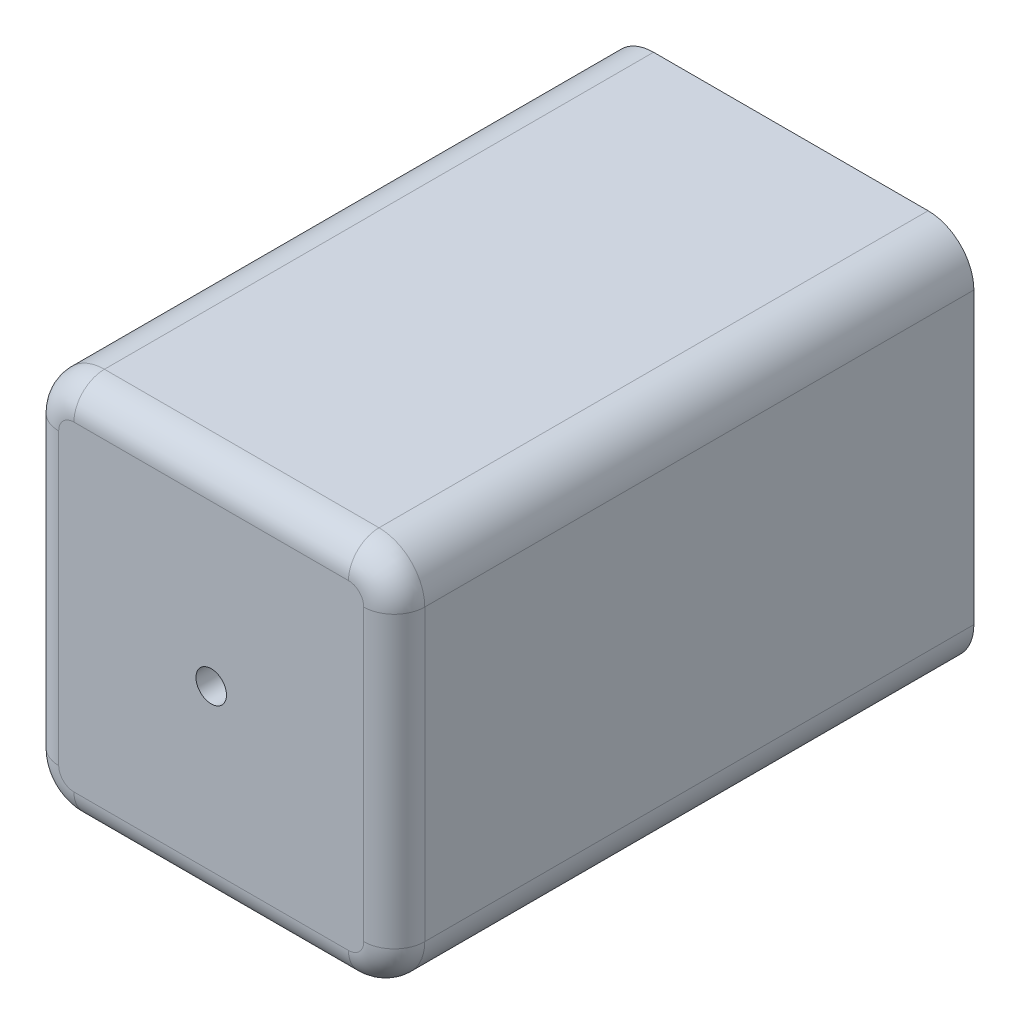
from build123d import *

# Parameters (mm, degrees)
SCHIZZO2_W                   = 190
SCHIZZO2_H                   = 125
ESTRUSIONE_ESTRUSIONE1_DEPTH = 120
RACCORDO1_R                  = 15
RACCORDO2_R                  = 10
SCHIZZO3_R                   = 5
TAGLIO_ESTRUSIONE1_DEPTH     = 191


with BuildPart() as part:
    # Schizzo2 → Estrusione-Estrusione1 (new body)
    with BuildSketch(Plane(origin=(0, 0, 0), x_dir=(0, 0, -1), z_dir=(1, 0, 0))):
        Rectangle(SCHIZZO2_W, SCHIZZO2_H)
    extrude(amount=ESTRUSIONE_ESTRUSIONE1_DEPTH)

    # Raccordo1
    raccordo1_edges = [part.edges().sort_by_distance(p)[0] for p in [
        (120, -62.5, 0),
        (0, -62.5, 0),
        (0, 62.5, 0),
        (120, 62.5, 0),
    ]]
    fillet(raccordo1_edges, radius=RACCORDO1_R)

    # Raccordo2
    raccordo2_edges = [part.edges().sort_by_distance(p)[0] for p in [
        (120, 0, 95),
        (0, 0, 95),
        (60, -62.5, 95),
        (60, 62.5, 95),
        (4.393398282, -58.106601718, 95),
        (4.393398282, 58.106601718, 95),
        (115.606601718, -58.106601718, 95),
        (115.606601718, 58.106601718, 95),
    ]]
    fillet(raccordo2_edges, radius=RACCORDO2_R)

    # Schizzo3 → Taglio-Estrusione1 (cut, through all)
    with BuildSketch(Plane(origin=(0, 0, -95), x_dir=(-1, 0, 0), z_dir=(0, 0, -1))):
        with Locations((-60, 0)):
            Circle(SCHIZZO3_R)
    extrude(amount=-TAGLIO_ESTRUSIONE1_DEPTH, mode=Mode.SUBTRACT)


solid = part.part
